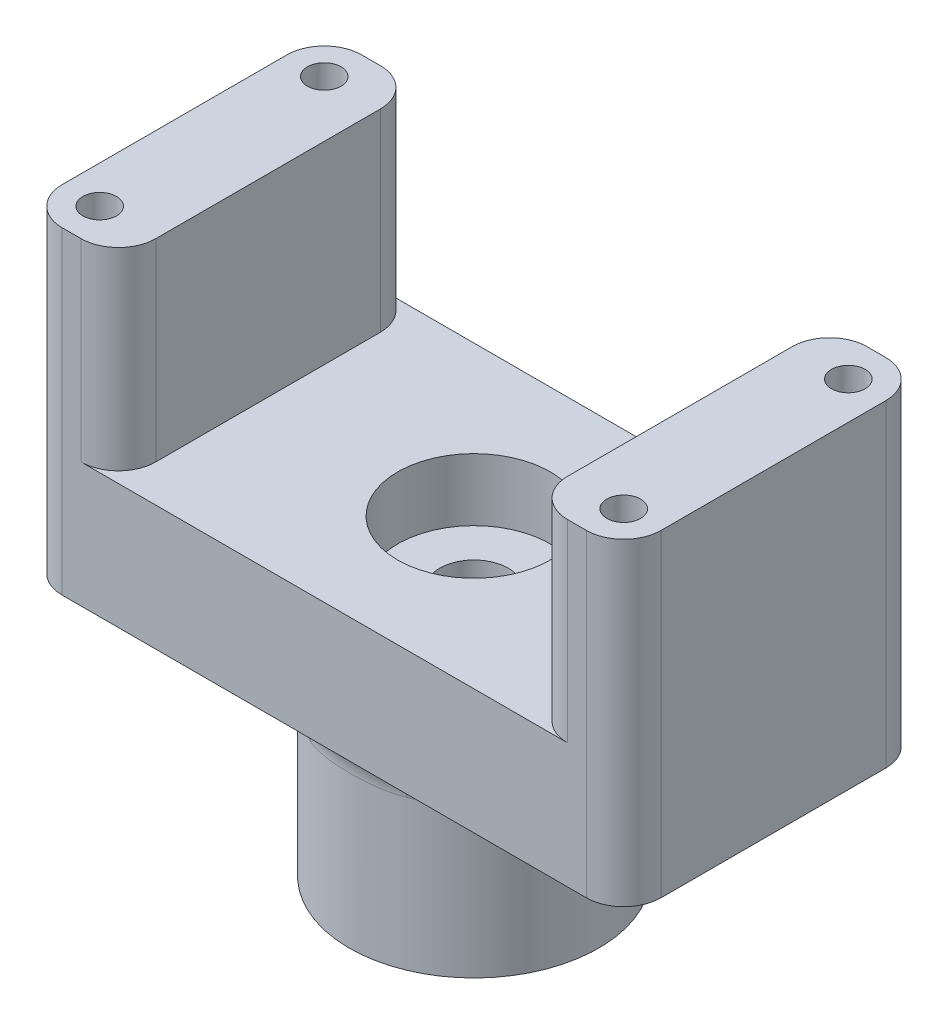
from build123d import *

# Parameters (mm, degrees)
SKETCH1_R                               = 1.35
BOSS_EXTRUDE1_DEPTH                     = 15.5
BOSS_EXTRUDE1_2_DEPTH                   = 15.5
SKETCH2_R                               = 1.35
BOSS_EXTRUDE2_DEPTH                     = 10
SKETCH4_R                               = 10
BOSS_EXTRUDE3_DEPTH                     = 15
CBORE_FOR_M5_HEX_HEAD_BOLT1_D           = 5.5
CBORE_FOR_M5_HEX_HEAD_BOLT1_CBORE_D     = 12.24
CBORE_FOR_M5_HEX_HEAD_BOLT1_CBORE_DEPTH = 5
FILLET1_R                               = 3


with BuildPart() as part:
    # Sketch1 → Boss-Extrude1 (new body)
    with BuildSketch(Plane(origin=(0, 0, 0), x_dir=(1, 0, 0), z_dir=(0, 1, 0))):
        with BuildLine():
            Line((21, 12), (16.5, 12))
            Line((16.5, 12), (16.5, -12))
            Line((16.5, -12), (21, -12))
            ThreePointArc((21, -12), (23.121320344, -11.121320344), (24, -9))
            Line((24, -9), (24, 9))
            ThreePointArc((24, 9), (23.121320344, 11.121320344), (21, 12))
        make_face()
        with Locations((21, -9)):
            Circle(SKETCH1_R, mode=Mode.SUBTRACT)
        with Locations((21, 9)):
            Circle(SKETCH1_R, mode=Mode.SUBTRACT)
    extrude(amount=BOSS_EXTRUDE1_DEPTH)



with BuildPart() as body_2:
    # Sketch1 → Boss-Extrude1 2 (new body)
    with BuildSketch(Plane(origin=(0, 0, 0), x_dir=(1, 0, 0), z_dir=(0, 1, 0))):
        with BuildLine():
            Line((-16.5, 12), (-21, 12))
            ThreePointArc((-21, 12), (-23.121320344, 11.121320344), (-24, 9))
            Line((-24, 9), (-24, -9))
            ThreePointArc((-24, -9), (-23.121320344, -11.121320344), (-21, -12))
            Line((-21, -12), (-16.5, -12))
            Line((-16.5, -12), (-16.5, 12))
        make_face()
        with Locations((-21, -9)):
            Circle(SKETCH1_R, mode=Mode.SUBTRACT)
        with Locations((-21, 9)):
            Circle(SKETCH1_R, mode=Mode.SUBTRACT)
    extrude(amount=BOSS_EXTRUDE1_2_DEPTH)


with BuildPart() as part_1:
    add(part.part)

    add(body_2.part)  # Boss-Extrude2 merges body 2
    # Sketch2 → Boss-Extrude2 (add)
    with BuildSketch(Plane(origin=(0, 0, 0), x_dir=(1, 0, 0), z_dir=(0, 1, 0))):
        with BuildLine():
            Line((24, 9), (24, -9))
            ThreePointArc((24, -9), (23.121320344, -11.121320344), (21, -12))
            Line((21, -12), (16.5, -12))
            Line((16.5, -12), (-16.5, -12))
            Line((-16.5, -12), (-21, -12))
            ThreePointArc((-21, -12), (-23.121320344, -11.121320344), (-24, -9))
            Line((-24, -9), (-24, 9))
            ThreePointArc((-24, 9), (-23.121320344, 11.121320344), (-21, 12))
            Line((-21, 12), (-16.5, 12))
            Line((-16.5, 12), (16.5, 12))
            Line((16.5, 12), (21, 12))
            ThreePointArc((21, 12), (23.121320344, 11.121320344), (24, 9))
        make_face()
        with Locations((21, 9)):
            Circle(SKETCH2_R, mode=Mode.SUBTRACT)
        with Locations((21, -9)):
            Circle(SKETCH2_R, mode=Mode.SUBTRACT)
        with Locations((-21, 9)):
            Circle(SKETCH2_R, mode=Mode.SUBTRACT)
        with Locations((-21, -9)):
            Circle(SKETCH2_R, mode=Mode.SUBTRACT)
    extrude(amount=-BOSS_EXTRUDE2_DEPTH)

    # Sketch4 → Boss-Extrude3 (add)
    with BuildSketch(Plane.XZ.offset(10)):
        Circle(SKETCH4_R)
    extrude(amount=BOSS_EXTRUDE3_DEPTH)

    # CBORE for M5 Hex Head Bolt1 (through all)
    with Locations(Plane.ZX):
        with Locations((0, 0)):
            CounterBoreHole(CBORE_FOR_M5_HEX_HEAD_BOLT1_D / 2, CBORE_FOR_M5_HEX_HEAD_BOLT1_CBORE_D / 2, CBORE_FOR_M5_HEX_HEAD_BOLT1_CBORE_DEPTH)

    # Fillet1
    fillet1_edges = [part_1.edges().sort_by_distance(p)[0] for p in [
        (-16.5, 7.75, -12),
        (-16.5, 7.75, 12),
        (16.5, 7.75, -12),
        (16.5, 7.75, 12),
        (-10, -10, 0),
    ]]
    fillet(fillet1_edges, radius=FILLET1_R)


solid = part_1.part
